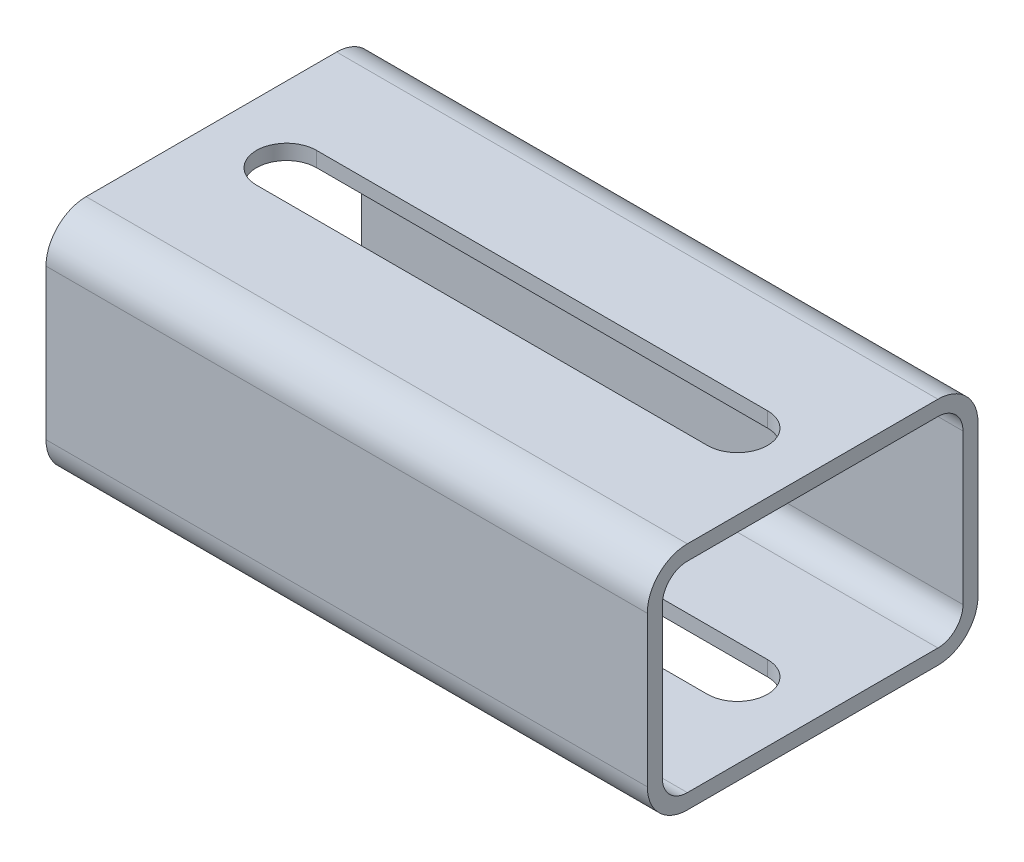
from build123d import *

# Parameters (mm, degrees)
EXTRUDE_THIN1_DEPTH = 60
CUT_EXTRUDE1_DEPTH  = 47


with BuildPart() as part:
    # Sketch1 → Extrude-Thin1 (new body, symmetric)
    with BuildSketch(Plane(origin=(0, 0, 0), x_dir=(0, 0, -1), z_dir=(1, 0, 0))):
        with BuildLine():
            Line((-33, 15), (-33, -15))
            ThreePointArc((-33, -15), (-30.656854249, -20.656854249), (-25, -23))
            Line((-25, -23), (25, -23))
            ThreePointArc((25, -23), (30.656854249, -20.656854249), (33, -15))
            Line((33, -15), (33, 15))
            ThreePointArc((33, 15), (30.656854249, 20.656854249), (25, 23))
            Line((25, 23), (-25, 23))
            ThreePointArc((-25, 23), (-30.656854249, 20.656854249), (-33, 15))
        make_face()
        with BuildLine():
            Line((-30, 15), (-30, -15))
            ThreePointArc((-30, -15), (-28.535533906, -18.535533906), (-25, -20))
            Line((-25, -20), (25, -20))
            ThreePointArc((25, -20), (28.535533906, -18.535533906), (30, -15))
            Line((30, -15), (30, 15))
            ThreePointArc((30, 15), (28.535533906, 18.535533906), (25, 20))
            Line((25, 20), (-25, 20))
            ThreePointArc((-25, 20), (-28.535533906, 18.535533906), (-30, 15))
        make_face(mode=Mode.SUBTRACT)
    extrude(amount=EXTRUDE_THIN1_DEPTH, both=True)

    # Sketch2 → Cut-Extrude1 (cut, through all)
    with BuildSketch(Plane(origin=(0, 23, 0), x_dir=(1, 0, 0), z_dir=(0, 1, 0))):
        with BuildLine():
            Line((-45, 6), (45, 6))
            ThreePointArc((45, 6), (51, 0), (45, -6))
            Line((45, -6), (-45, -6))
            ThreePointArc((-45, -6), (-51, 0), (-45, 6))
        make_face()
    extrude(amount=-CUT_EXTRUDE1_DEPTH, mode=Mode.SUBTRACT)


solid = part.part
